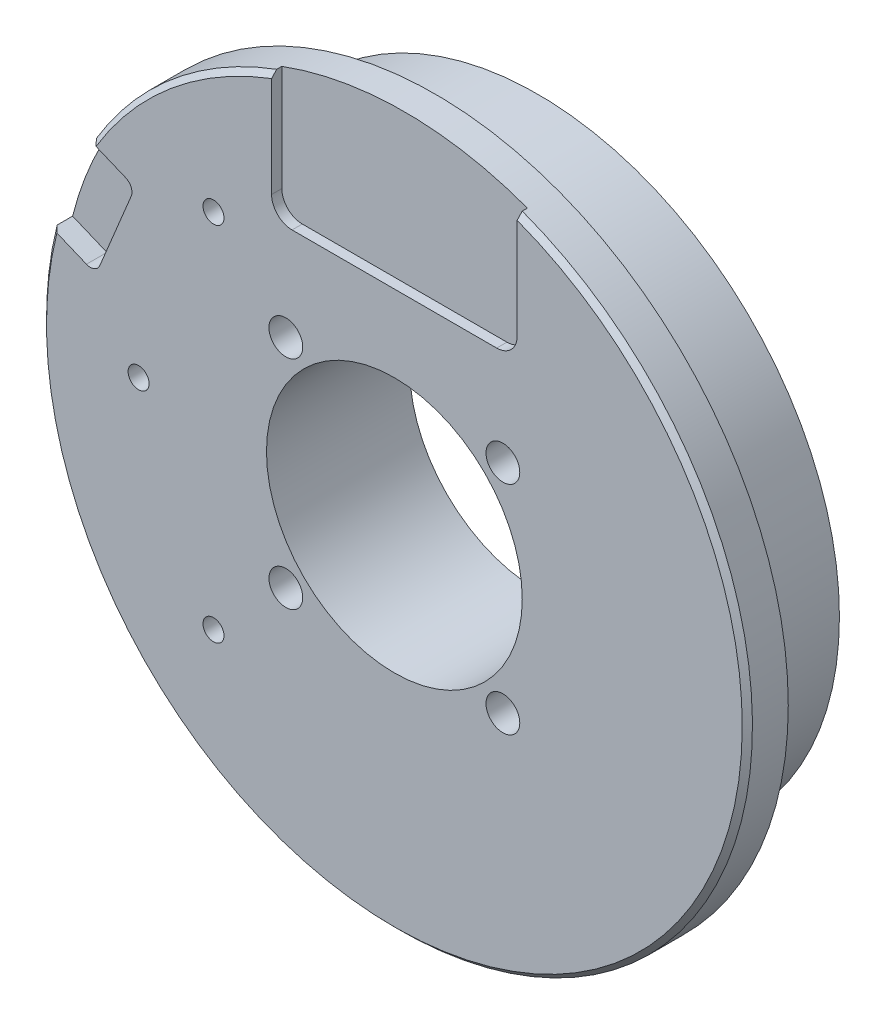
from build123d import *

# Parameters (mm, degrees)
SKETCH1_R               = 29.5
BOSS_EXTRUDE1_DEPTH     = 10
SKETCH2_R               = 34.5
BOSS_EXTRUDE2_DEPTH     = 4
SKETCH3_R               = 12.5
CUT_EXTRUDE1_DEPTH      = 15
M4_TAPPED_HOLE1_D       = 3.3
M2_5_TAPPED_HOLE1_D     = 2.05
M2_5_TAPPED_HOLE1_DEPTH = 6.35
M2_5_TAPPED_HOLE1_TIP   = 0.615882135
CHAMFER1_SIZE           = 0.5
CUT_EXTRUDE2_DEPTH      = 2
CUT_EXTRUDE4_DEPTH      = 1


with BuildPart() as part:
    # Sketch1 → Boss-Extrude1 (new body)
    with BuildSketch(Plane.XY):
        Circle(SKETCH1_R)
    extrude(amount=BOSS_EXTRUDE1_DEPTH)

    # Sketch2 → Boss-Extrude2 (add)
    with BuildSketch(Plane.XY.offset(10)):
        Circle(SKETCH2_R)
    extrude(amount=BOSS_EXTRUDE2_DEPTH)

    # Sketch3 → Cut-Extrude1 (cut, through all)
    with BuildSketch(Plane.XY.offset(14)):
        Circle(SKETCH3_R)
    extrude(amount=-CUT_EXTRUDE1_DEPTH, mode=Mode.SUBTRACT)

    # M4 Tapped Hole1 (through all)
    with Locations(Plane.XY.offset(14)):
        with Locations((-10.606601718, 10.606601718), (10.606601718, 10.606601718), (10.606601718, -10.606601718), (-10.606601718, -10.606601718)):
            Hole(M4_TAPPED_HOLE1_D / 2)

    # M2.5 Tapped Hole1
    with Locations(Plane.XY.offset(14)):
        with Locations((-17.67766953, -17.67766953), (-25, 0), (-17.67766953, 17.67766953)):
            Hole(M2_5_TAPPED_HOLE1_D / 2, depth=M2_5_TAPPED_HOLE1_DEPTH)
            with Locations((0, 0, -(M2_5_TAPPED_HOLE1_DEPTH + M2_5_TAPPED_HOLE1_TIP / 2))):  # 118° drill point
                Cone(0, M2_5_TAPPED_HOLE1_D / 2, M2_5_TAPPED_HOLE1_TIP, mode=Mode.SUBTRACT)

    # Chamfer1
    chamfer1_edges = [part.edges().sort_by_distance(p)[0] for p in [
        (-34.5, 0, 14),
    ]]
    chamfer(chamfer1_edges, length=CHAMFER1_SIZE)

    # Sketch9 → Cut-Extrude2 (cut)
    with BuildSketch(Plane.XY.offset(14)):
        with BuildLine():
            Line((-33.450745653, 8.44379152), (-30.091742903, 7.052447025))
            ThreePointArc((-30.091742903, 7.052447025), (-29.326376039, 7.052447025), (-28.785179939, 7.593643125))
            Line((-28.785179939, 7.593643125), (-25.72371248, 14.984679385))
            ThreePointArc((-25.72371248, 14.984679385), (-25.72371248, 15.75004625), (-26.26490858, 16.29124235))
            Line((-26.26490858, 16.29124235), (-29.62391133, 17.682586845))
            ThreePointArc((-29.62391133, 17.682586845), (-31.873843872, 13.202578417), (-33.450745653, 8.44379152))
        make_face()
    extrude(amount=-CUT_EXTRUDE2_DEPTH, mode=Mode.SUBTRACT)

    # Sketch11 → Cut-Extrude4 (cut)
    with BuildSketch(Plane.XY.offset(14)):
        with BuildLine():
            Line((-12, 32.345787979), (-12, 22))
            ThreePointArc((-12, 22), (-11.414213562, 20.585786438), (-10, 20))
            Line((-10, 20), (10, 20))
            ThreePointArc((10, 20), (11.414213562, 20.585786438), (12, 22))
            Line((12, 22), (12, 32.345787979))
            ThreePointArc((12, 32.345787979), (0, 34.5), (-12, 32.345787979))
        make_face()
    extrude(amount=-CUT_EXTRUDE4_DEPTH, mode=Mode.SUBTRACT)


solid = part.part
